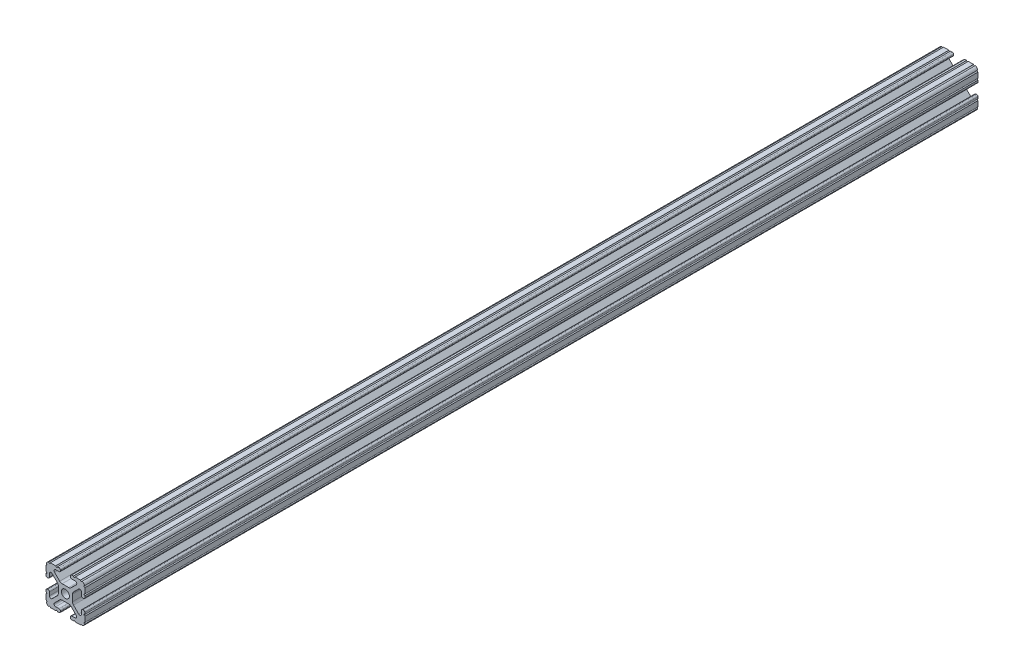
from build123d import *

# Parameters (mm, degrees)
BOSS_EXTRUDE1_DEPTH     = 304.8
SKETCH5_R               = 0.55245
CUT_EXTRUDE1_DEPTH      = 305.8
CUT_EXTRUDE1_DEPTH_BACK = 305.8
SKETCH6_W               = 31.75
SKETCH6_H               = 25.4
CUT_EXTRUDE2_DEPTH      = 12.7


with BuildPart() as part:
    # Sketch4 → Boss-Extrude1 (new body, symmetric)
    with BuildSketch(Plane.XY):
        with BuildLine():
            Line((4.190365, -12.7), (10.11729625, -12.7))
            ThreePointArc((10.11729625, -12.7), (11.943543585, -11.943543585), (12.7, -10.11729625))
            Line((12.7, -10.11729625), (12.7, -4.190365))
            ThreePointArc((12.7, -4.190365), (12.42492494, -3.52627506), (11.760835, -3.2512))
            Line((11.760835, -3.2512), (11.429365, -3.2512))
            ThreePointArc((11.429365, -3.2512), (10.76527506, -3.52627506), (10.4902, -4.190365))
            Line((10.4902, -4.190365), (10.4902, -6.348478019))
            ThreePointArc((10.4902, -6.348478019), (9.830707141, -7.335478831), (8.666460301, -7.103895736))
            Line((8.666460301, -7.103895736), (5.299899128, -3.737334563))
            ThreePointArc((5.299899128, -3.737334563), (4.817571085, -3.015479634), (4.6482, -2.16399369))
            Line((4.6482, -2.16399369), (4.6482, 0))
            Line((4.6482, 0), (2.6035, 0))
            ThreePointArc((2.6035, 0), (1.840952505, -1.840952505), (0, -2.6035))
            Line((0, -2.6035), (0, -4.6482))
            Line((0, -4.6482), (2.16399369, -4.6482))
            ThreePointArc((2.16399369, -4.6482), (3.015479634, -4.817571085), (3.737334563, -5.299899128))
            Line((3.737334563, -5.299899128), (7.103895736, -8.666460301))
            ThreePointArc((7.103895736, -8.666460301), (7.335478831, -9.830707141), (6.348478019, -10.4902))
            Line((6.348478019, -10.4902), (4.190365, -10.4902))
            ThreePointArc((4.190365, -10.4902), (3.52627506, -10.76527506), (3.2512, -11.429365))
            Line((3.2512, -11.429365), (3.2512, -11.760835))
            ThreePointArc((3.2512, -11.760835), (3.52627506, -12.42492494), (4.190365, -12.7))
        make_face()
    extrude(amount=BOSS_EXTRUDE1_DEPTH, both=True)

    # Sketch5 → Cut-Extrude1 (cut, two sides)
    with BuildSketch(Plane.XY) as cut_extrude1_sk:
        with Locations((10.356153152, -12.7)):
            Circle(SKETCH5_R)
        with Locations((5.796028019, -12.7)):
            Circle(SKETCH5_R)
        with Locations((12.7, -10.356153152)):
            Circle(SKETCH5_R)
        with Locations((12.7, -5.796028019)):
            Circle(SKETCH5_R)
    extrude(amount=CUT_EXTRUDE1_DEPTH, mode=Mode.SUBTRACT)
    extrude(cut_extrude1_sk.sketch, amount=-CUT_EXTRUDE1_DEPTH_BACK, mode=Mode.SUBTRACT)

    # Mirror1: part across plane


with BuildPart() as part_1:
    add(part.part)
    add(part.part.mirror(Plane(origin=(0, 0, 0), x_dir=(0, 0, 1), z_dir=(1, 0, 0))))

    # Mirror2: part across plane


with BuildPart() as part_2:
    add(part_1.part)
    add(part_1.part.mirror(Plane.ZX))

    # Sketch6 → Cut-Extrude2 (cut, symmetric)
    with BuildSketch(Plane(origin=(0, 0, 0), x_dir=(1, 0, 0), z_dir=(0, 1, 0))):
        with Locations((-0.060001566, -292.1)):
            Rectangle(SKETCH6_W, SKETCH6_H)
    extrude(amount=CUT_EXTRUDE2_DEPTH, both=True, mode=Mode.SUBTRACT)


solid = part_2.part
